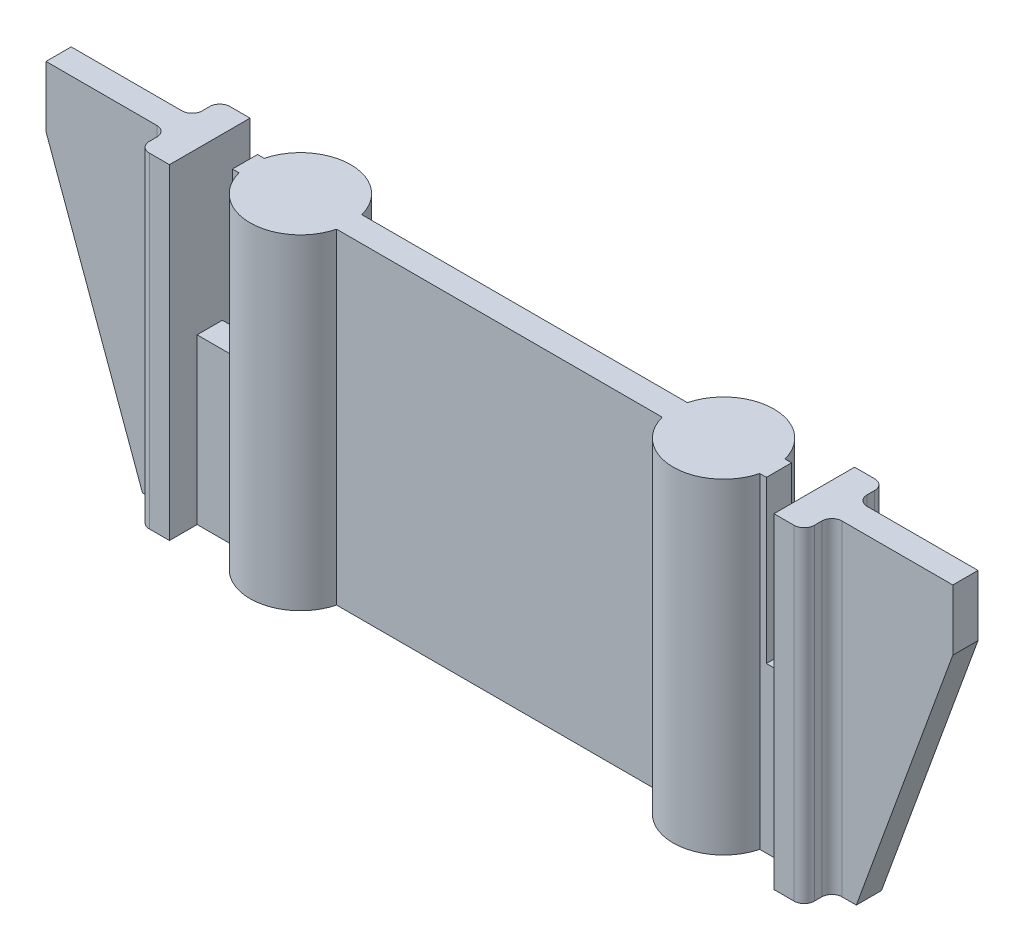
from build123d import *

# Parameters (mm, degrees)
BOSS_EXTRUDE1_DEPTH      = 32.31
CUT_EXTRUDE1_DEPTH       = 25
SKETCH3_W                = 3.5
SKETCH3_H                = 16.162716407
CUT_EXTRUDE2_DEPTH       = 16
SKETCH4_W                = 3
SKETCH4_H                = 8
BOSS_EXTRUDE2_DEPTH      = 32.31
FILLET1_R                = 1
FILLET2_R                = 1
M3_CLEARANCE_HOLE1_D     = 3.6
M3_CLEARANCE_HOLE1_DEPTH = 16
M3_CLEARANCE_HOLE1_TIP   = 1.081549114
CUT_EXTRUDE3_DEPTH       = 4


with BuildPart() as part:
    # Sketch1 → Boss-Extrude1 (new body)
    with BuildSketch(Plane(origin=(0, 0, 0), x_dir=(1, 0, 0), z_dir=(0, 1, 0))):
        with BuildLine():
            Line((-45, 13.25), (-25.841229183, 13.25))
            ThreePointArc((-25.841229183, 13.25), (-21, 17), (-16.158770817, 13.25))
            Line((-16.158770817, 13.25), (16.158770817, 13.25))
            ThreePointArc((16.158770817, 13.25), (21, 17), (25.841229183, 13.25))
            Line((25.841229183, 13.25), (45, 13.25))
            Line((45, 13.25), (45, 10.75))
            Line((45, 10.75), (25.841229183, 10.75))
            ThreePointArc((25.841229183, 10.75), (21, 7), (16.158770817, 10.75))
            Line((16.158770817, 10.75), (-16.158770817, 10.75))
            ThreePointArc((-16.158770817, 10.75), (-21, 7), (-25.841229183, 10.75))
            Line((-25.841229183, 10.75), (-45, 10.75))
            Line((-45, 10.75), (-45, 13.25))
        make_face()
    extrude(amount=BOSS_EXTRUDE1_DEPTH)

    # Sketch2 → Cut-Extrude1 (cut)
    with BuildSketch(Plane.XY.offset(-10.75)):
        Polygon((-35.420614591, 0), (-45, 26.272359302), (-58.390365854, 22.525370437), (-53.81468831, -5.500654521), (-35.420614591, -4.763359631), align=None)
        Polygon((53.81468831, -5.500654521), (35.420614591, -4.763359631), (35.420614591, 0), (45, 26.272359302), (58.390365854, 22.525370437), align=None)
    extrude(amount=-CUT_EXTRUDE1_DEPTH, mode=Mode.SUBTRACT)

    # Sketch3 → Cut-Extrude2 (cut)
    with BuildSketch(Plane(origin=(0, 32.31, 0), x_dir=(1, 0, 0), z_dir=(0, 1, 0))):
        with Locations((-28.25, 12.031966157)):
            Rectangle(SKETCH3_W, SKETCH3_H)
        with Locations((28.25, 12.031966157)):
            Rectangle(SKETCH3_W, SKETCH3_H)
    extrude(amount=-CUT_EXTRUDE2_DEPTH, mode=Mode.SUBTRACT)

    # Sketch4 → Boss-Extrude2 (add)
    with BuildSketch(Plane.XZ):
        with Locations((-31.5, -12)):
            Rectangle(SKETCH4_W, SKETCH4_H)
    boss_extrude2 = extrude(amount=-BOSS_EXTRUDE2_DEPTH)

    # Fillet1
    fillet1_edges = [part.edges().sort_by_distance(p)[0] for p in [
        (-33, 16.155, -10.75),
        (-33, 16.155, -8),
        (-33, 16.155, -13.25),
        (-33, 16.155, -16),
    ]]
    fillet(fillet1_edges, radius=FILLET1_R)

    # Mirror1: Boss-Extrude2 across plane
    add(boss_extrude2.mirror(Plane(origin=(0, 0, 0), x_dir=(0, 0, 1), z_dir=(1, 0, 0))))

    # Fillet2
    fillet2_edges = [part.edges().sort_by_distance(p)[0] for p in [
        (33, 16.155, -10.75),
        (33, 16.155, -8),
        (33, 16.155, -13.25),
        (33, 16.155, -16),
    ]]
    fillet(fillet2_edges, radius=FILLET2_R)

    # M3 Clearance Hole1
    with Locations(Plane(origin=(0, 0, 0), x_dir=(-1, 0, 0), z_dir=(0, -1, 0))):
        with Locations((-21, 12), (21, 12)):
            Hole(M3_CLEARANCE_HOLE1_D / 2, depth=M3_CLEARANCE_HOLE1_DEPTH)
            with Locations((0, 0, -(M3_CLEARANCE_HOLE1_DEPTH + M3_CLEARANCE_HOLE1_TIP / 2))):  # 118° drill point
                Cone(0, M3_CLEARANCE_HOLE1_D / 2, M3_CLEARANCE_HOLE1_TIP, mode=Mode.SUBTRACT)

    # Sketch7 → Cut-Extrude3 (cut)
    with BuildSketch(Plane(origin=(0, 10, 0), x_dir=(-1, 0, 0), z_dir=(0, -1, 0))):
        Polygon((-24.15, 13.818653348), (-24.15, 10.181346652), (-21, 8.362693304), (-17.85, 10.181346652), (-17.85, 13.818653348), (-17.85, 20.157444089), (-24.15, 20.157444089), align=None)
    cut_extrude3 = extrude(amount=CUT_EXTRUDE3_DEPTH, mode=Mode.SUBTRACT)

    # Mirror2: Cut-Extrude3 across plane
    add(cut_extrude3.mirror(Plane(origin=(0, 0, 0), x_dir=(0, 0, 1), z_dir=(1, 0, 0))), mode=Mode.SUBTRACT)


solid = part.part
